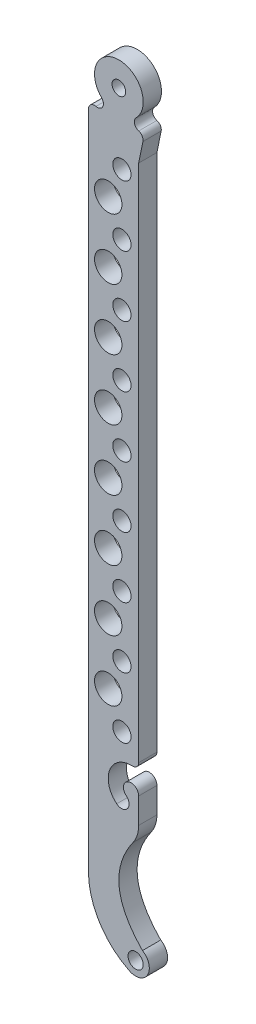
from build123d import *

# Parameters (mm, degrees)
SKETCH_1_R          = 2.5
EXTRUDE_1_DEPTH     = 6
CUT_EXTRUDE_1_DEPTH = 7.0000001
HOLE_WIZARD_M41_D   = 4.5
CUT_EXTRUDE_2_DEPTH = 7.0000001
FILLET_1_R          = 2
SKETCH_9_R          = 3
SKETCH_9_R_2        = 4.5
CUT_EXTRUDE_4_DEPTH = 7.0000001
FILLET_4_R          = 2
FILLET_5_R          = 10


with BuildPart() as part:
    # Эскиз1 → Бобышка-Вытянуть1 (new body)
    with BuildSketch(Plane.XY):
        with BuildLine():
            Line((6.5, -18.132817334), (6.5, -210))
            add(Edge.make_bspline(
                [(7.75, -241.602885683), (-7.119806504, -226.33675702), (6.5, -210)],
                knots=[0, 0, 0, 1, 1, 1], degree=2))
            ThreePointArc((7.75, -241.602885683), (9.397114317, -247.75), (3.25, -249.397114317))
            ThreePointArc((3.25, -249.397114317), (-6.419807766, -240.569690394), (-10, -227.975611669))
            Line((-10, -227.975611669), (-10, 0))
            ThreePointArc((-10, 0), (1.006528746, 9.949216044), (9.797379977, -2.002834391))
            Line((9.797379977, -2.002834391), (6.5, -18.132817334))
        make_face()
        with Locations((5.5, -245.5)):
            Circle(SKETCH_1_R, mode=Mode.SUBTRACT)
    extrude(amount=EXTRUDE_1_DEPTH)

    # Эскиз2 → Вырез-Вытянуть1 (cut, through all)
    with BuildSketch(Plane.XY.offset(6)):
        with BuildLine():
            Line((6.5, -198.230414456), (6.5, -191.159346644))
            ThreePointArc((6.5, -191.159346644), (-2.545169709, -194.568344894), (-0.718217458, -204.060373635))
            ThreePointArc((-0.718217458, -204.060373635), (2.797841421, -203.689793061), (2.427260847, -200.173734182))
            ThreePointArc((2.427260847, -200.173734182), (2.923396053, -195.974106866), (6.5, -198.230414456))
        make_face()
    extrude(amount=-CUT_EXTRUDE_1_DEPTH, mode=Mode.SUBTRACT)

    # Отверстие с зазором M41 (through all)
    with Locations(Plane.XY.offset(6)):
        with Locations((0, 0)):
            Hole(HOLE_WIZARD_M41_D / 2)

    # Эскиз6 → Вырез-Вытянуть2 (cut, through all)
    with BuildSketch(Plane.XY.offset(6)):
        with BuildLine():
            ThreePointArc((5.656854249, -5.656854249), (0, 8), (-5.656854249, -5.656854249))
            ThreePointArc((-5.656854249, -5.656854249), (-5.656854249, -8.485281374), (-8.485281374, -8.485281374))
            ThreePointArc((-8.485281374, -8.485281374), (0, 12), (8.485281374, -8.485281374))
            ThreePointArc((8.485281374, -8.485281374), (5.656854249, -8.485281374), (5.656854249, -5.656854249))
        make_face()
    extrude(amount=-CUT_EXTRUDE_2_DEPTH, mode=Mode.SUBTRACT)

    # Скругление1
    fillet_1_edges = [part.edges().sort_by_distance(p)[0] for p in [
        (8.468890039, -8.501484892, 3),
        (-10, -6.633249581, 3),
    ]]
    fillet(fillet_1_edges, radius=FILLET_1_R)

    # Эскиз9 → Вырез-Вытянуть4 (cut, through all)
    with BuildSketch(Plane.XY.offset(6)):
        with Locations((1, -22.672779762)):
            Circle(SKETCH_9_R)
        with Locations((1, -42.672779762)):
            Circle(SKETCH_9_R)
        with Locations((1, -62.672779762)):
            Circle(SKETCH_9_R)
        with Locations((1, -82.672779762)):
            Circle(SKETCH_9_R)
        with Locations((1, -102.672779762)):
            Circle(SKETCH_9_R)
        with Locations((1, -122.672779762)):
            Circle(SKETCH_9_R)
        with Locations((1, -142.672779762)):
            Circle(SKETCH_9_R)
        with Locations((1, -162.672779762)):
            Circle(SKETCH_9_R)
        with Locations((1, -182.672779762)):
            Circle(SKETCH_9_R)
        with Locations((-3.5, -32.672779762)):
            Circle(SKETCH_9_R_2)
        with Locations((-3.5, -52.672779762)):
            Circle(SKETCH_9_R_2)
        with Locations((-3.5, -72.672779762)):
            Circle(SKETCH_9_R_2)
        with Locations((-3.5, -92.672779762)):
            Circle(SKETCH_9_R_2)
        with Locations((-3.5, -112.672779762)):
            Circle(SKETCH_9_R_2)
        with Locations((-3.5, -132.672779762)):
            Circle(SKETCH_9_R_2)
        with Locations((-3.5, -152.672779762)):
            Circle(SKETCH_9_R_2)
        with Locations((-3.5, -172.672779762)):
            Circle(SKETCH_9_R_2)
    extrude(amount=-CUT_EXTRUDE_4_DEPTH, mode=Mode.SUBTRACT)

    # Скругление4
    fillet_4_edges = [part.edges().sort_by_distance(p)[0] for p in [
        (6.5, -191.159346644, 3),
    ]]
    fillet(fillet_4_edges, radius=FILLET_4_R)

    # Скругление5
    fillet_5_edges = [part.edges().sort_by_distance(p)[0] for p in [
        (6.5, -210, 3),
    ]]
    fillet(fillet_5_edges, radius=FILLET_5_R)


solid = part.part
